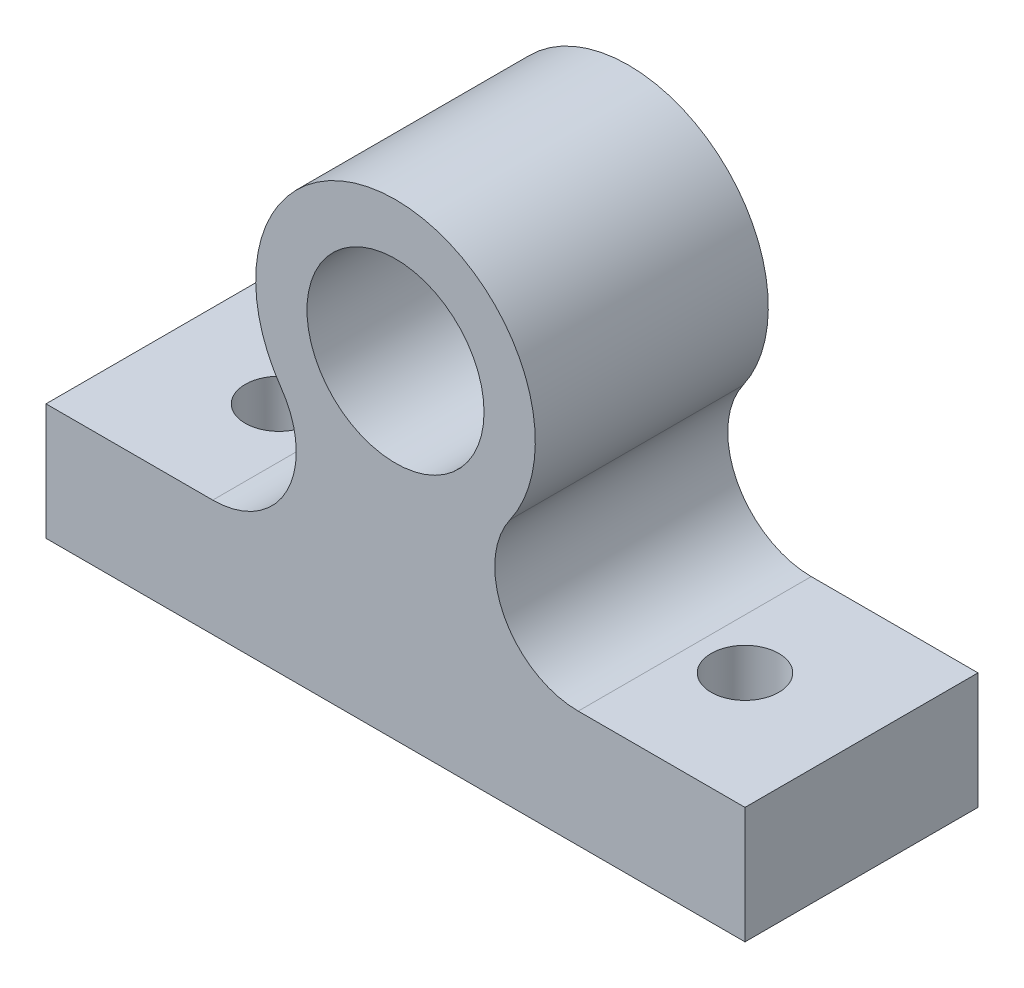
from build123d import *

# Parameters (mm, degrees)
SKETCH1_R               = 4.826
BOSS_EXTRUDE1_DEPTH     = 12.7
SKETCH2_R               = 1.8415
CUT_EXTRUDE1_DEPTH      = 20.165748301
CUT_EXTRUDE1_DEPTH_BACK = 7.35


with BuildPart() as part:
    # Sketch1 → Boss-Extrude1 (new body)
    with BuildSketch(Plane.XY):
        with BuildLine():
            Line((0, 0), (38.1, 0))
            Line((38.1, 0), (38.1, 6.35))
            Line((38.1, 6.35), (29.010834454, 6.35))
            ThreePointArc((29.010834454, 6.35), (24.972383208, 8.802433287), (25.286109599, 13.516783004))
            ThreePointArc((25.286109599, 13.516783004), (19.05, 25.515748301), (12.813890401, 13.516783004))
            ThreePointArc((12.813890401, 13.516783004), (13.127616792, 8.802433287), (9.089165546, 6.35))
            Line((9.089165546, 6.35), (0, 6.35))
            Line((0, 6.35), (0, 0))
        make_face()
        with Locations((19.05, 17.895748301)):
            Circle(SKETCH1_R, mode=Mode.SUBTRACT)
    extrude(amount=BOSS_EXTRUDE1_DEPTH)

    # Sketch2 → Cut-Extrude1 (cut, two sides)
    with BuildSketch(Plane(origin=(0, 6.35, 0), x_dir=(1, 0, 0), z_dir=(0, 1, 0))) as cut_extrude1_sk:
        with Locations((6.35, -6.35)):
            Circle(SKETCH2_R)
        with Locations((31.75, -6.35)):
            Circle(SKETCH2_R)
    extrude(amount=CUT_EXTRUDE1_DEPTH, mode=Mode.SUBTRACT)
    extrude(cut_extrude1_sk.sketch, amount=-CUT_EXTRUDE1_DEPTH_BACK, mode=Mode.SUBTRACT)


solid = part.part
